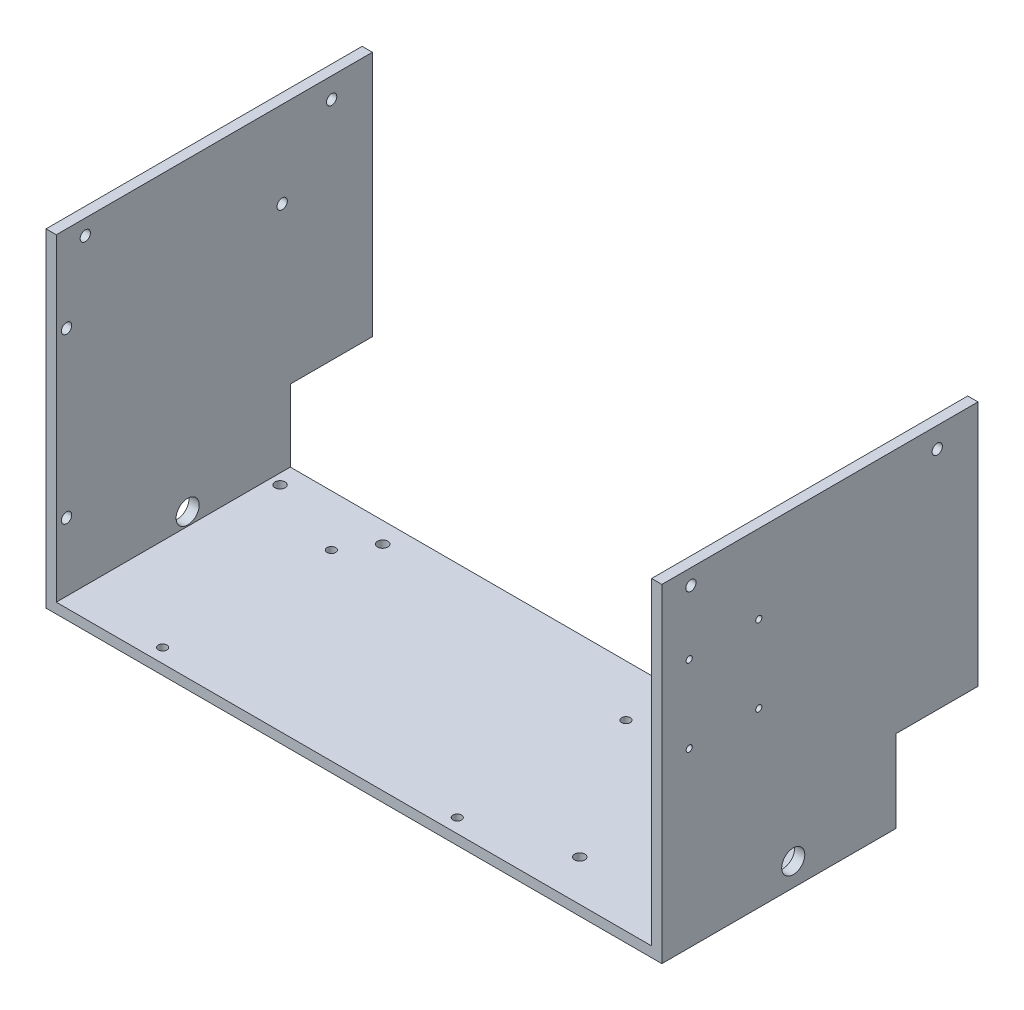
from build123d import *

# Parameters (mm, degrees)
SKETCH1_W            = 381
SKETCH1_H            = 429.26
BOSS_EXTRUDE1_DEPTH  = 6.35
SKETCH2_W            = 254
SKETCH2_H            = 203.2
CUT_EXTRUDE1_DEPTH   = 6.35
SKETCH3_W            = 381
SKETCH3_H            = 73.66
CUT_EXTRUDE2_DEPTH   = 6.35
SKETCH4_W            = 254
SKETCH4_H            = 6.35
CUT_EXTRUDE3_DEPTH   = 73.66
SKETCH6_W            = 6.35
SKETCH6_H            = 195.58
BOSS_EXTRUDE2_DEPTH  = 171.45
SKETCH7_W            = 6.35
SKETCH7_H            = 195.58
BOSS_EXTRUDE3_DEPTH  = 158.75
SKETCH8_W            = 6.35
SKETCH8_H            = 165.1
BOSS_EXTRUDE4_DEPTH  = 50.8
SKETCH9_W            = 6.35
SKETCH9_H            = 158.75
CUT_EXTRUDE4_DEPTH   = 50.8
SKETCH10_W           = 6.899940386
SKETCH10_H           = 177.8
BOSS_EXTRUDE5_DEPTH  = 50.8
SKETCH11_W           = 6.35
SKETCH11_H           = 171.45
CUT_EXTRUDE5_DEPTH   = 50.8
SKETCH13_W           = 0.549940386
SKETCH13_H           = 171.45
CUT_EXTRUDE6_DEPTH   = 50.8
SKETCH14_W           = 6.899940386
SKETCH14_H           = 177.8
CUT_EXTRUDE7_DEPTH   = 50.8
SKETCH15_W           = 6.35
SKETCH15_H           = 165.1
CUT_EXTRUDE8_DEPTH   = 50.8
SKETCH16_W           = 6.35
SKETCH16_H           = 144.78
BOSS_EXTRUDE6_DEPTH  = 25.4
SKETCH17_W           = 6.35
SKETCH17_H           = 144.78
BOSS_EXTRUDE7_DEPTH  = 19.05
SKETCH19_W           = 6.35
SKETCH19_H           = 139.7
BOSS_EXTRUDE8_DEPTH  = 50.8
SKETCH20_W           = 6.35
SKETCH20_H           = 195.58
BOSS_EXTRUDE9_DEPTH  = 31.75
SKETCH21_W           = 6.35
SKETCH21_H           = 139.7
BOSS_EXTRUDE10_DEPTH = 50.8
SKETCH22_W           = 6.35
SKETCH22_H           = 195.58
BOSS_EXTRUDE11_DEPTH = 50.8
SKETCH23_W           = 6.35
SKETCH23_H           = 50.8
BOSS_EXTRUDE12_DEPTH = 12.7
SKETCH24_W           = 6.35
SKETCH24_H           = 195.58
BOSS_EXTRUDE13_DEPTH = 12.7
SKETCH26_W           = 381
SKETCH26_H           = 210.82
CUT_EXTRUDE9_DEPTH   = 12.7
SKETCH27_R           = 7.14375
CUT_EXTRUDE12_DEPTH  = 8.89
SKETCH29_R           = 7.14375
CUT_EXTRUDE13_DEPTH  = 8.89
SKETCH31_R           = 3.175
CUT_EXTRUDE14_DEPTH  = 12.7
SKETCH36_R           = 1.905
CUT_EXTRUDE17_DEPTH  = 12.7
SKETCH37_R           = 2.667
CUT_EXTRUDE18_DEPTH  = 17.78
SKETCH38_R           = 3.175
CUT_EXTRUDE19_DEPTH  = 17.78
SKETCH39_R           = 3.175
CUT_EXTRUDE20_DEPTH  = 17.78
SKETCH41_R           = 3.175
CUT_EXTRUDE21_DEPTH  = 15.24
SKETCH42_R           = 3.302
CUT_EXTRUDE22_DEPTH  = 12.7
SKETCH43_R           = 3.302
SKETCH43_R_2         = 3.175
SKETCH43_R_3         = 3.175000007
BOSS_EXTRUDE14_DEPTH = 6.35


with BuildPart() as part:
    # Sketch1 → Boss-Extrude1 (new body)
    with BuildSketch(Plane(origin=(0, 0, 0), x_dir=(1, 0, 0), z_dir=(0, 1, 0))):
        with Locations((190.5, 214.63)):
            Rectangle(SKETCH1_W, SKETCH1_H)
    extrude(amount=BOSS_EXTRUDE1_DEPTH)

    # Sketch2 → Cut-Extrude1 (cut)
    with BuildSketch(Plane(origin=(0, 6.35, 0), x_dir=(1, 0, 0), z_dir=(0, 1, 0))):
        with Locations((190.5, 101.6)):
            Rectangle(SKETCH2_W, SKETCH2_H)
    extrude(amount=-CUT_EXTRUDE1_DEPTH, mode=Mode.SUBTRACT)

    # Sketch3 → Cut-Extrude2 (cut)
    with BuildSketch(Plane(origin=(0, 6.35, 0), x_dir=(1, 0, 0), z_dir=(0, 1, 0))):
        with Locations((190.5, 36.83)):
            Rectangle(SKETCH3_W, SKETCH3_H)
    extrude(amount=-CUT_EXTRUDE2_DEPTH, mode=Mode.SUBTRACT)

    # Sketch4 → Cut-Extrude3 (cut)
    with BuildSketch(Plane.XY.offset(-203.2)):
        with Locations((190.5, 3.175)):
            Rectangle(SKETCH4_W, SKETCH4_H)
    extrude(amount=-CUT_EXTRUDE3_DEPTH, mode=Mode.SUBTRACT)

    # Sketch6 → Boss-Extrude2 (add)
    with BuildSketch(Plane(origin=(0, 6.35, 0), x_dir=(1, 0, 0), z_dir=(0, 1, 0))):
        with Locations((377.825, 331.47)):
            Rectangle(SKETCH6_W, SKETCH6_H)
    extrude(amount=BOSS_EXTRUDE2_DEPTH)

    # Sketch7 → Boss-Extrude3 (add)
    with BuildSketch(Plane(origin=(0, 6.35, 0), x_dir=(1, 0, 0), z_dir=(0, 1, 0))):
        with Locations((3.175, 331.47)):
            Rectangle(SKETCH7_W, SKETCH7_H)
    extrude(amount=BOSS_EXTRUDE3_DEPTH)

    # Sketch8 → Boss-Extrude4 (add)
    with BuildSketch(Plane(origin=(0, 0, -429.26), x_dir=(-1, 0, 0), z_dir=(0, 0, -1))):
        with Locations((-3.175, 82.55)):
            Rectangle(SKETCH8_W, SKETCH8_H)
    extrude(amount=BOSS_EXTRUDE4_DEPTH)

    # Sketch9 → Cut-Extrude4 (cut)
    with BuildSketch(Plane.XY.offset(-233.68)):
        with Locations((3.175, 85.725)):
            Rectangle(SKETCH9_W, SKETCH9_H)
    extrude(amount=-CUT_EXTRUDE4_DEPTH, mode=Mode.SUBTRACT)

    # Sketch10 → Boss-Extrude5 (add)
    with BuildSketch(Plane(origin=(0, 0, -429.26), x_dir=(-1, 0, 0), z_dir=(0, 0, -1))):
        with Locations((-377.550029807, 88.9)):
            Rectangle(SKETCH10_W, SKETCH10_H)
    extrude(amount=BOSS_EXTRUDE5_DEPTH)

    # Sketch11 → Cut-Extrude5 (cut)
    with BuildSketch(Plane.XY.offset(-233.68)):
        with Locations((377.825, 92.075)):
            Rectangle(SKETCH11_W, SKETCH11_H)
    extrude(amount=-CUT_EXTRUDE5_DEPTH, mode=Mode.SUBTRACT)

    # Sketch13 → Cut-Extrude6 (cut)
    with BuildSketch(Plane.XY.offset(-429.26)):
        with Locations((374.375029807, 92.075)):
            Rectangle(SKETCH13_W, SKETCH13_H)
    extrude(amount=-CUT_EXTRUDE6_DEPTH, mode=Mode.SUBTRACT)

    # Sketch14 → Cut-Extrude7 (cut)
    with BuildSketch(Plane(origin=(0, 0, -480.06), x_dir=(-1, 0, 0), z_dir=(0, 0, -1))):
        with Locations((-377.550029807, 88.9)):
            Rectangle(SKETCH14_W, SKETCH14_H)
    extrude(amount=-CUT_EXTRUDE7_DEPTH, mode=Mode.SUBTRACT)

    # Sketch15 → Cut-Extrude8 (cut)
    with BuildSketch(Plane(origin=(0, 0, -480.06), x_dir=(-1, 0, 0), z_dir=(0, 0, -1))):
        with Locations((-3.175, 82.55)):
            Rectangle(SKETCH15_W, SKETCH15_H)
    extrude(amount=-CUT_EXTRUDE8_DEPTH, mode=Mode.SUBTRACT)

    # Sketch16 → Boss-Extrude6 (add)
    with BuildSketch(Plane(origin=(0, 177.8, 0), x_dir=(1, 0, 0), z_dir=(0, 1, 0))):
        with Locations((377.825, 356.87)):
            Rectangle(SKETCH16_W, SKETCH16_H)
    extrude(amount=BOSS_EXTRUDE6_DEPTH)

    # Sketch17 → Boss-Extrude7 (add)
    with BuildSketch(Plane(origin=(0, 165.1, 0), x_dir=(1, 0, 0), z_dir=(0, 1, 0))):
        with Locations((3.175, 356.87)):
            Rectangle(SKETCH17_W, SKETCH17_H)
    extrude(amount=-BOSS_EXTRUDE7_DEPTH)

    # Sketch19 → Boss-Extrude8 (add)
    with BuildSketch(Plane(origin=(0, 0, -429.26), x_dir=(-1, 0, 0), z_dir=(0, 0, -1))):
        with Locations((-3.175, 120.65)):
            Rectangle(SKETCH19_W, SKETCH19_H)
    extrude(amount=BOSS_EXTRUDE8_DEPTH)

    # Sketch20 → Boss-Extrude9 (add)
    with BuildSketch(Plane(origin=(0, 190.5, 0), x_dir=(1, 0, 0), z_dir=(0, 1, 0))):
        with Locations((3.175, 382.27)):
            Rectangle(SKETCH20_W, SKETCH20_H)
    extrude(amount=-BOSS_EXTRUDE9_DEPTH)

    # Sketch21 → Boss-Extrude10 (add)
    with BuildSketch(Plane(origin=(0, 0, -429.26), x_dir=(-1, 0, 0), z_dir=(0, 0, -1))):
        with Locations((-377.825, 133.35)):
            Rectangle(SKETCH21_W, SKETCH21_H)
    extrude(amount=BOSS_EXTRUDE10_DEPTH)

    # Sketch22 → Boss-Extrude11 (add)
    with BuildSketch(Plane(origin=(0, 203.2, 0), x_dir=(1, 0, 0), z_dir=(0, 1, 0))):
        with Locations((377.825, 382.27)):
            Rectangle(SKETCH22_W, SKETCH22_H)
    extrude(amount=-BOSS_EXTRUDE11_DEPTH)

    # Sketch23 → Boss-Extrude12 (add)
    with BuildSketch(Plane.XZ.offset(-63.5)):
        with Locations((377.825, -454.66)):
            Rectangle(SKETCH23_W, SKETCH23_H)
    extrude(amount=BOSS_EXTRUDE12_DEPTH)

    # Sketch24 → Boss-Extrude13 (add)
    with BuildSketch(Plane(origin=(0, 190.5, 0), x_dir=(1, 0, 0), z_dir=(0, 1, 0))):
        with Locations((3.175, 382.27)):
            Rectangle(SKETCH24_W, SKETCH24_H)
    extrude(amount=BOSS_EXTRUDE13_DEPTH)

    # Sketch26 → Cut-Extrude9 (cut)
    with BuildSketch(Plane(origin=(0, 6.35, 0), x_dir=(1, 0, 0), z_dir=(0, 1, 0))):
        with Locations((190.5, 179.07)):
            Rectangle(SKETCH26_W, SKETCH26_H)
    extrude(amount=-CUT_EXTRUDE9_DEPTH, mode=Mode.SUBTRACT)

    # Sketch27 → Cut-Extrude12 (cut)
    with BuildSketch(Plane.ZY):
        with Locations((-365.76, 14.224)):
            Circle(SKETCH27_R)
    extrude(amount=-CUT_EXTRUDE12_DEPTH, mode=Mode.SUBTRACT)

    # Sketch29 → Cut-Extrude13 (cut)
    with BuildSketch(Plane(origin=(381, 0, 0), x_dir=(0, 0, -1), z_dir=(1, 0, 0))):
        with Locations((365.76, 14.224)):
            Circle(SKETCH29_R)
    extrude(amount=-CUT_EXTRUDE13_DEPTH, mode=Mode.SUBTRACT)

    # Sketch31 → Cut-Extrude14 (cut)
    with BuildSketch(Plane(origin=(0, 6.35, 0), x_dir=(1, 0, 0), z_dir=(0, 1, 0))):
        with Locations((368.3, 416.56)):
            Circle(SKETCH31_R)
        with Locations((304.8, 416.56)):
            Circle(SKETCH31_R)
        with Locations((12.7, 416.56)):
            Circle(SKETCH31_R)
        with Locations((76.2, 416.56)):
            Circle(SKETCH31_R)
    extrude(amount=-CUT_EXTRUDE14_DEPTH, mode=Mode.SUBTRACT)

    # Sketch36 → Cut-Extrude17 (cut)
    with BuildSketch(Plane(origin=(381, 0, 0), x_dir=(0, 0, -1), z_dir=(1, 0, 0))):
        with Locations((344.451335942, 154.548846533)):
            Circle(SKETCH36_R)
        with Locations((301.398335942, 154.5512)):
            Circle(SKETCH36_R)
        with Locations((344.451335942, 106.7992)):
            Circle(SKETCH36_R)
        with Locations((301.398335942, 106.7992)):
            Circle(SKETCH36_R)
    extrude(amount=-CUT_EXTRUDE17_DEPTH, mode=Mode.SUBTRACT)

    # Sketch37 → Cut-Extrude18 (cut)
    with BuildSketch(Plane(origin=(0, 6.35, 0), x_dir=(1, 0, 0), z_dir=(0, 1, 0))):
        with Locations((63.5, 397.51)):
            Circle(SKETCH37_R)
        with Locations((63.5, 293.116)):
            Circle(SKETCH37_R)
        with Locations((245.7704, 293.116)):
            Circle(SKETCH37_R)
        with Locations((245.7704, 397.51)):
            Circle(SKETCH37_R)
    extrude(amount=-CUT_EXTRUDE18_DEPTH, mode=Mode.SUBTRACT)

    # Sketch38 → Cut-Extrude19 (cut)
    with BuildSketch(Plane(origin=(0, 6.35, 0), x_dir=(1, 0, 0), z_dir=(0, 1, 0))):
        with Locations((304.8, 309.88)):
            Circle(SKETCH38_R)
        with Locations((361.95, 337.82)):
            Circle(SKETCH38_R)
    extrude(amount=-CUT_EXTRUDE19_DEPTH, mode=Mode.SUBTRACT)

    # Sketch39 → Cut-Extrude20 (cut)
    with BuildSketch(Plane.ZY):
        with Locations((-454.84383327, 190.5)):
            Circle(SKETCH39_R)
        with Locations((-302.443833262, 193.675)):
            Circle(SKETCH39_R)
    extrude(amount=-CUT_EXTRUDE20_DEPTH, mode=Mode.SUBTRACT)

    # Sketch41 → Cut-Extrude21 (cut)
    with BuildSketch(Plane.ZY):
        with Locations((-424.2308, 149.9108)):
            Circle(SKETCH41_R)
        with Locations((-290.8808, 48.387)):
            Circle(SKETCH41_R)
        with Locations((-290.8808, 149.9108)):
            Circle(SKETCH41_R)
    extrude(amount=-CUT_EXTRUDE21_DEPTH, mode=Mode.SUBTRACT)

    # Sketch42 → Cut-Extrude22 (cut)
    with BuildSketch(Plane(origin=(381, 0, 0), x_dir=(0, 0, -1), z_dir=(1, 0, 0))):
        with Locations((454.843833262, 190.5)):
            Circle(SKETCH42_R)
        with Locations((302.443833262, 193.675)):
            Circle(SKETCH42_R)
    extrude(amount=-CUT_EXTRUDE22_DEPTH, mode=Mode.SUBTRACT)

    # Sketch43 → Boss-Extrude14 (add)
    with BuildSketch(Plane(origin=(381, 0, 0), x_dir=(0, 0, -1), z_dir=(1, 0, 0))):
        with Locations((302.443833262, 193.675)):
            Circle(SKETCH43_R)
        with Locations((302.443833262, 193.675)):
            Circle(SKETCH43_R_2, mode=Mode.SUBTRACT)
        with Locations((454.843833262, 190.5)):
            Circle(SKETCH43_R)
        with Locations((454.843833262, 190.5)):
            Circle(SKETCH43_R_3, mode=Mode.SUBTRACT)
    extrude(amount=-BOSS_EXTRUDE14_DEPTH)


solid = part.part
